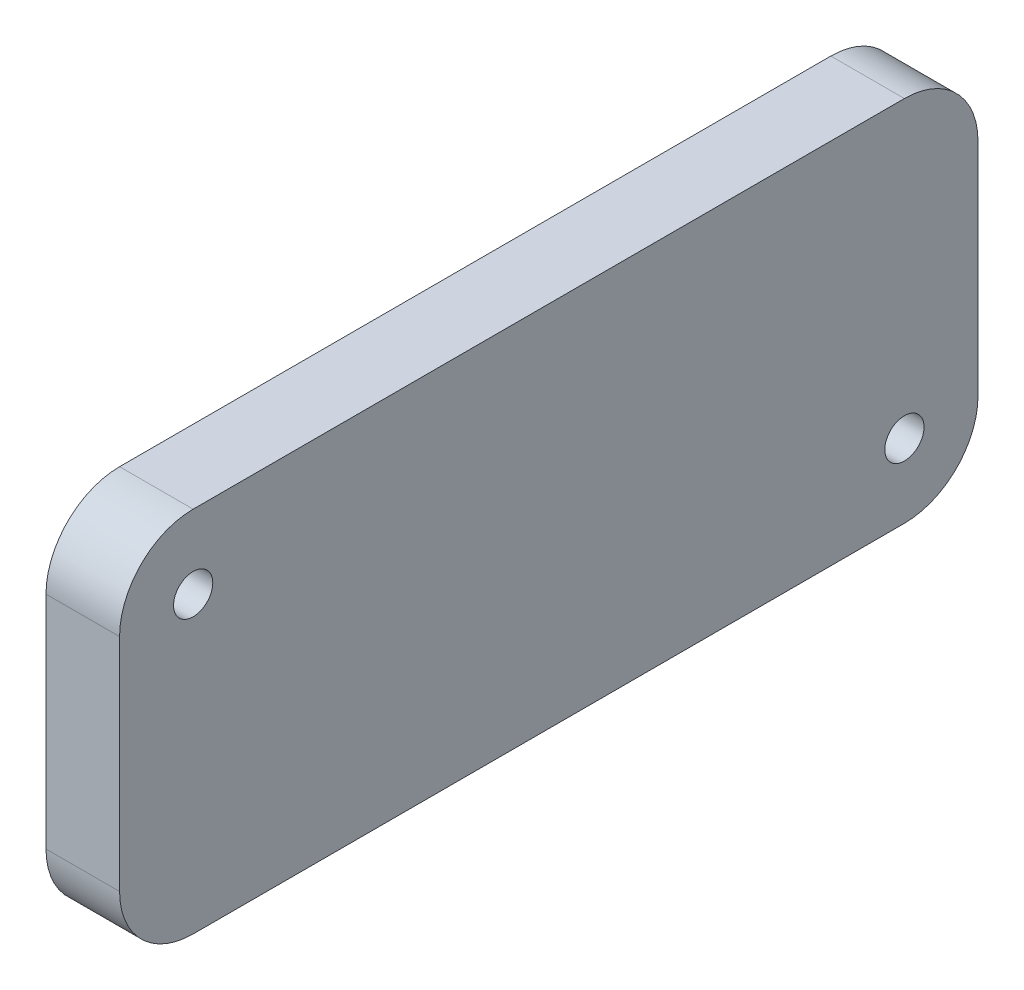
from build123d import *

# Parameters (mm, degrees)
ESBO_O1_W                = 35
ESBO_O1_H                = 15
ESBO_O1_R                = 0.8
RESSALTO_EXTRUS_O1_DEPTH = 3
FILETE1_R                = 3


with BuildPart() as part:
    # Esboço1 → Ressalto-extrusão1 (new body)
    with BuildSketch(Plane(origin=(0, 0, 0), x_dir=(0, 0, -1), z_dir=(1, 0, 0))):
        Rectangle(ESBO_O1_W, ESBO_O1_H)
        with Locations((-14.5, 4.5)):
            Circle(ESBO_O1_R, mode=Mode.SUBTRACT)
        with Locations((14.5, -4.5)):
            Circle(ESBO_O1_R, mode=Mode.SUBTRACT)
    extrude(amount=RESSALTO_EXTRUS_O1_DEPTH)

    # Filete1
    filete1_edges = [part.edges().sort_by_distance(p)[0] for p in [
        (1.5, -7.5, -17.5),
        (1.5, -7.5, 17.5),
        (1.5, 7.5, 17.5),
        (1.5, 7.5, -17.5),
    ]]
    fillet(filete1_edges, radius=FILETE1_R)


solid = part.part
